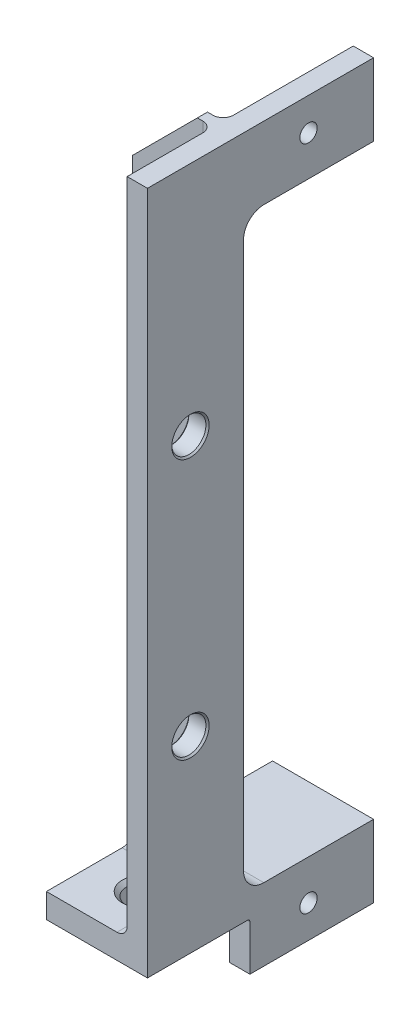
from build123d import *

# Parameters (mm, degrees)
BOSS_EXTRUDE1_DEPTH   = 3.175
BOSS_EXTRUDE2_DEPTH   = 12.60732
FILLET1_R             = 1.5875
FILLET2_R             = 3.175
CUT_EXTRUDE1_DEPTH    = 16
F_6_32_TAPPED_HOLE1_D = 2.7051
SKETCH10_R            = 2.667
CUT_EXTRUDE2_DEPTH    = 4.175
CHAMFER1_SIZE         = 0.254
FILLET3_R             = 1.5875
FILLET4_R             = 0.39624


with BuildPart() as part:
    # Sketch1 → Boss-Extrude1 (new body)
    with BuildSketch(Plane(origin=(0, 0, 0), x_dir=(0, 0, -1), z_dir=(1, 0, 0))):
        Polygon((27.813, 57.15), (27.813, 45.847999998), (7.5, 45.847999998), (7.5, -45.847999998), (27.813, -45.847999998), (27.813, -57.15), (8.5, -57.15), (8.5, -49.657999998), (-7.5, -49.657999998), (-7.5, 57.15), align=None)
    extrude(amount=BOSS_EXTRUDE1_DEPTH)

    # Sketch2 → Boss-Extrude2 (add)
    with BuildSketch(Plane.ZY):
        Polygon((7.5, -49.657999998), (7.5, -45.847999998), (-5.9125, -45.847999998), (-5.9125, 57.15), (-7.5, 57.15), (-7.5, -45.847999998), (-27.813, -45.847999998), (-27.813, -49.657999998), align=None)
    extrude(amount=BOSS_EXTRUDE2_DEPTH)

    # Sketch4 → #10 Clearance Hole1 (revolve, cut)
    with BuildSketch(Plane(origin=(-5.10794, -49.657999998, 0), x_dir=(0, 0, -1), z_dir=(1, 0, 0))):
        Polygon((0, 0), (0, 3.81), (3.1242, 3.81), (2.4892, 3.175), (2.4892, 0.635), (3.1242, 0), align=None)
    revolve(axis=Axis((-5.10794, -56.007999998, 0), (0, 1, 0)), mode=Mode.SUBTRACT)

    # Fillet1
    fillet1_edges = [part.edges().sort_by_distance(p)[0] for p in [
        (-6.30366, -45.847999998, -5.9125),
    ]]
    fillet(fillet1_edges, radius=FILLET1_R)

    # Fillet2
    fillet2_edges = [part.edges().sort_by_distance(p)[0] for p in [
        (-4.71616, -45.847999998, -7.5),
        (1.5875, 45.847999998, -7.5),
    ]]
    fillet(fillet2_edges, radius=FILLET2_R)

    # Sketch6 → Cut-Extrude1 (cut, through all)
    with BuildSketch(Plane(origin=(0, 0, -7.5), x_dir=(-1, 0, 0), z_dir=(0, 0, -1))):
        Polygon((2.447319972, 57.15), (12.607319972, 57.15), (12.607319972, 46.99), align=None)
    extrude(amount=-CUT_EXTRUDE1_DEPTH, mode=Mode.SUBTRACT)

    # #6-32 Tapped Hole1 (through all)
    with Locations(Plane(origin=(3.175, 0, 0), x_dir=(0, 0, -1), z_dir=(1, 0, 0))):
        with Locations((17.653, 52.07)):
            f_6_32_tapped_hole1 = Hole(F_6_32_TAPPED_HOLE1_D / 2)

    # Sketch10 → Cut-Extrude2 (cut, through all)
    with BuildSketch(Plane.ZY):
        with Locations((0.7874, 20.32)):
            Circle(SKETCH10_R)
    cut_extrude2 = extrude(amount=-CUT_EXTRUDE2_DEPTH, mode=Mode.SUBTRACT)

    # Mirror2: Cut-Extrude2 across plane
    add(cut_extrude2.mirror(Plane.ZX), mode=Mode.SUBTRACT)

    # Chamfer1
    chamfer1_edges = [part.edges().sort_by_distance(p)[0] for p in [
        (3.175, 20.32, -1.8796),
        (0, 20.32, -1.8796),
        (3.175, -20.32, -1.8796),
        (0, -20.32, -1.8796),
    ]]
    chamfer(chamfer1_edges, length=CHAMFER1_SIZE)

    # Fillet3
    fillet3_edges = [part.edges().sort_by_distance(p)[0] for p in [
        (0, 6.444750001, -5.9125),
        (0, -45.383032013, -5.447532015),
        (0, -49.657999998, -18.1565),
        (0, 49.911499999, -7.5),
        (0, -45.847999998, 1.5875),
    ]]
    fillet(fillet3_edges, radius=FILLET3_R)

    # Mirror1: #6-32 Tapped Hole1 across plane
    add(f_6_32_tapped_hole1.mirror(Plane.ZX), mode=Mode.SUBTRACT)

    # Fillet4
    fillet4_edges = [part.edges().sort_by_distance(p)[0] for p in [
        (0.79375, -49.657999998, -8.5),
    ]]
    fillet(fillet4_edges, radius=FILLET4_R)


solid = part.part
